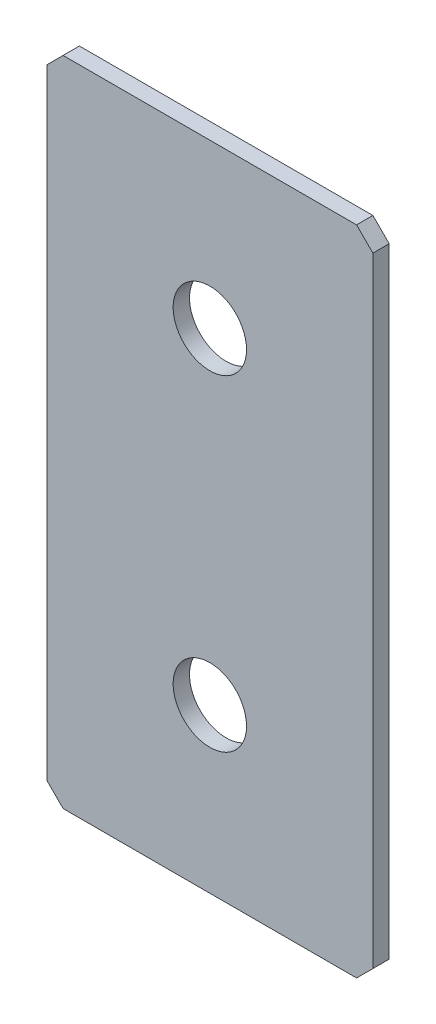
from build123d import *

# Parameters (mm, degrees)
SKETCH_1_W        = 40
SKETCH_1_H        = 80
EXTRUDE_1_DEPTH   = 2
CHAMFER_1_SIZE    = 2
HOLE_WIZARD_M81_D = 9


with BuildPart() as part:
    # Эскиз1 → Бобышка-Вытянуть1 (new body)
    with BuildSketch(Plane.XY):
        Rectangle(SKETCH_1_W, SKETCH_1_H)
    extrude(amount=EXTRUDE_1_DEPTH)

    # Фаска1
    chamfer_1_edges = [part.edges().sort_by_distance(p)[0] for p in [
        (20, -40, 1),
        (-20, -40, 1),
        (-20, 40, 1),
        (20, 40, 1),
    ]]
    chamfer(chamfer_1_edges, length=CHAMFER_1_SIZE)

    # Отверстие с зазором M81 (through all)
    with Locations(Plane.XY.offset(2)):
        with Locations((0, -20), (0, 20)):
            Hole(HOLE_WIZARD_M81_D / 2)


solid = part.part
